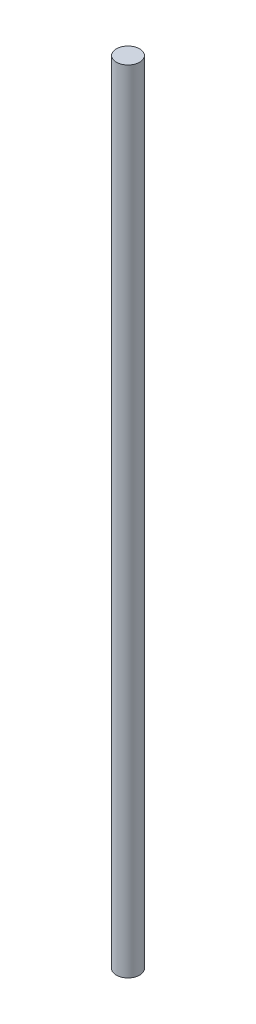
from build123d import *

# Parameters (mm, degrees)
SKETCH1_R           = 5
BOSS_EXTRUDE1_DEPTH = 340


with BuildPart() as part:
    # Sketch1 → Boss-Extrude1 (new body)
    with BuildSketch(Plane(origin=(0, 0, 0), x_dir=(1, 0, 0), z_dir=(0, 1, 0))):
        Circle(SKETCH1_R)
    extrude(amount=BOSS_EXTRUDE1_DEPTH)


solid = part.part
